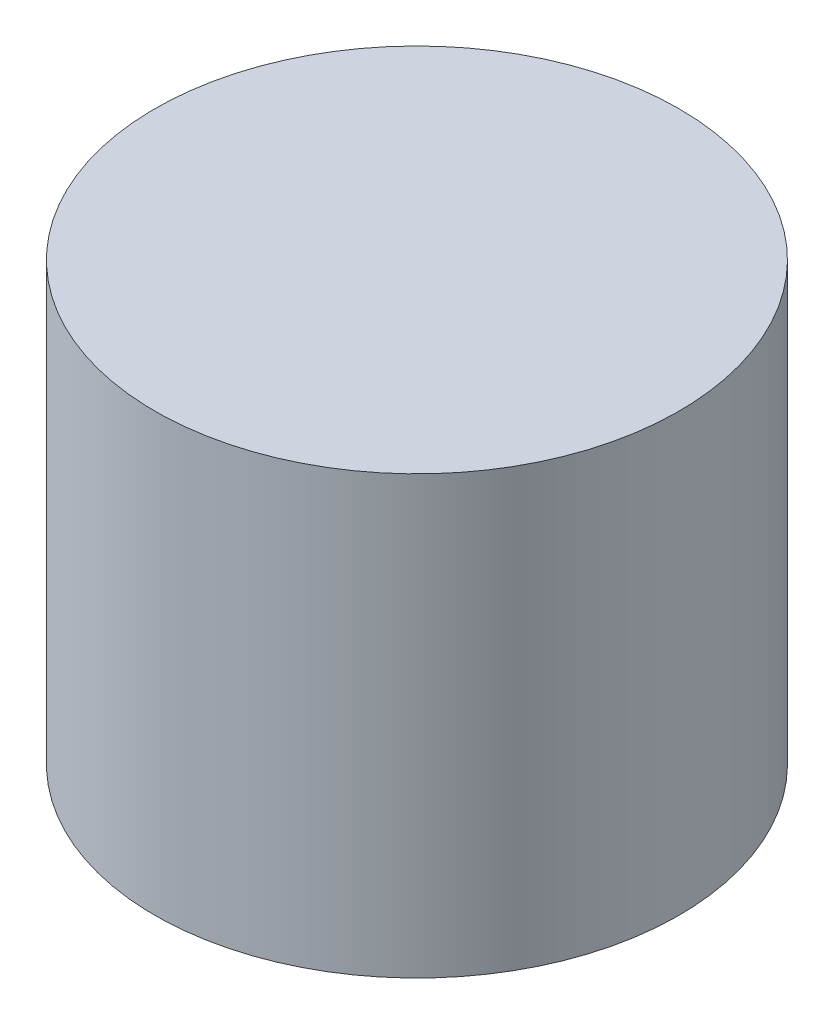
from build123d import *

# Parameters (mm, degrees)
SKETCH_1_W = 90
SKETCH_1_H = 150


with BuildPart() as part:
    # Эскиз1 → Повернуть1 (revolve)
    with BuildSketch(Plane.XY):
        with Locations((45, 75)):
            Rectangle(SKETCH_1_W, SKETCH_1_H)
    revolve(axis=Axis((0, 0, 0), (0, 1, 0)))

    # Эскиз3 → Вырез-Повернуть1 (revolve, cut)
    with BuildSketch(Plane(origin=(0, 0, 0), x_dir=(0, 0, -1), z_dir=(1, 0, 0))):
        with BuildLine():
            Line((0, 0), (0, 70))
            ThreePointArc((0, 70), (49.497474683, 49.497474683), (70, 0))
            Line((70, 0), (0, 0))
        make_face()
    revolve(axis=Axis((0, 0, 0), (0, 1, 0)), mode=Mode.SUBTRACT)


solid = part.part
